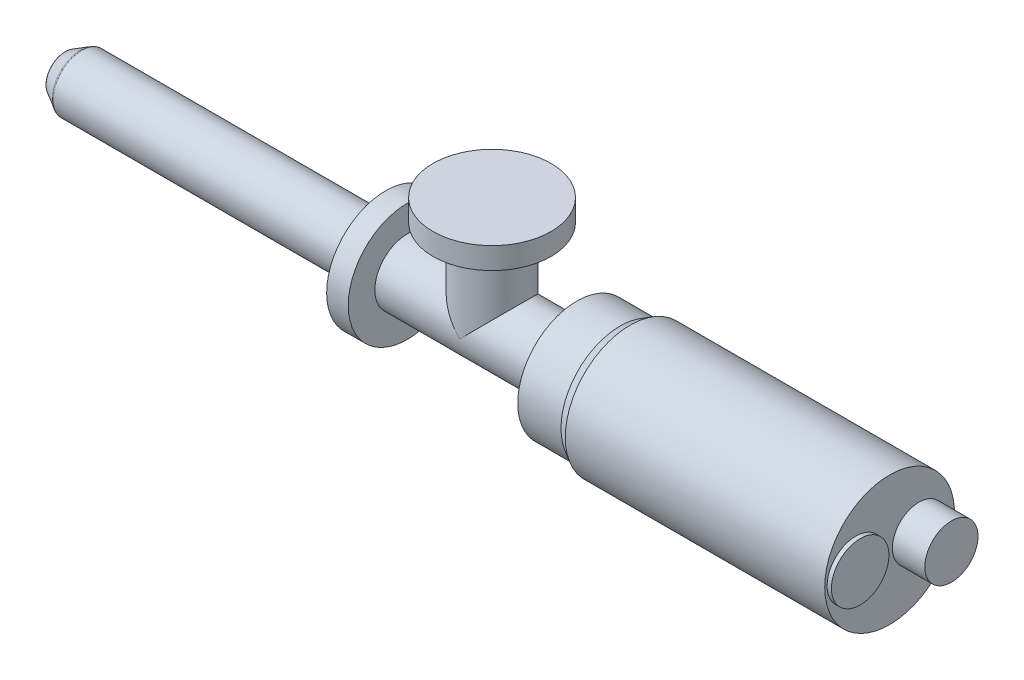
from build123d import *

# Parameters (mm, degrees)
SKETCH2_R           = 19.05
BOSS_EXTRUDE1_DEPTH = 62.484
SKETCH3_R           = 34.671
BOSS_EXTRUDE2_DEPTH = 12.7
SKETCH4_R           = 15.621
BOSS_EXTRUDE3_DEPTH = 19.05
SKETCH5_R           = 16.891
BOSS_EXTRUDE4_DEPTH = 2.54
FILLET1_R           = 1.524
SKETCH6_R           = 3.175
CUT_EXTRUDE1_DEPTH  = 12.7


with BuildPart() as part:
    # Sketch1 → Revolve1 (revolve)
    with BuildSketch(Plane.XY, mode=Mode.PRIVATE) as revolve1_sk:
        Polygon((0, 0), (0, 11.049), (9.722694003, 16.6624), (188.722, 16.6624), (188.722, 34.671), (201.422, 34.671), (201.422, 19.05), (300.99, 19.05), (300.99, 34.671), (326.39, 34.671), (332.329202219, 38.1), (484.729202219, 38.1), (484.729202219, 0), align=None)
    revolve(revolve1_sk.sketch.rotate(Axis((0, 0, 0), (1, 0, 0)), 90), axis=Axis((0, 0, 0), (1, 0, 0)))  # turned: the seam where the file's is

    # Sketch2 → Boss-Extrude1 (add)
    with BuildSketch(Plane(origin=(0, 0, 0), x_dir=(1, 0, 0), z_dir=(0, 1, 0))):
        with Locations(Location((251.206, 0, 0), (0, 0, 270))):  # turned: the seam where the file's is
            Circle(SKETCH2_R)
    extrude(amount=BOSS_EXTRUDE1_DEPTH)

    # Sketch3 → Boss-Extrude2 (add)
    with BuildSketch(Plane(origin=(0, 62.484, 0), x_dir=(1, 0, 0), z_dir=(0, 1, 0))):
        with Locations(Location((251.206, 0, 0), (0, 0, 270))):  # turned: the seam where the file's is
            Circle(SKETCH3_R)
    extrude(amount=-BOSS_EXTRUDE2_DEPTH)

    # Sketch4 → Boss-Extrude3 (add)
    with BuildSketch(Plane(origin=(484.729202219, 0, 0), x_dir=(0, 0, -1), z_dir=(1, 0, 0))):
        with Locations(Location((17.272, 0, 0), (0, 0, 180))):  # turned: the seam where the file's is
            Circle(SKETCH4_R)
    extrude(amount=BOSS_EXTRUDE3_DEPTH)

    # Sketch5 → Boss-Extrude4 (add)
    with BuildSketch(Plane(origin=(484.729202219, 0, 0), x_dir=(0, 0, -1), z_dir=(1, 0, 0))):
        with Locations(Location((-19.812, 0, 0), (0, 0, 180))):  # turned: the seam where the file's is
            Circle(SKETCH5_R)
    extrude(amount=BOSS_EXTRUDE4_DEPTH)

    # Fillet1
    fillet1_edges = [part.edges().sort_by_distance(p)[0] for p in [
        (9.722694003, 0, -16.6624),
        (0, 0, -11.049),
    ]]
    fillet(fillet1_edges, radius=FILLET1_R)

    # Sketch6 → Cut-Extrude1 (cut)
    with BuildSketch(Plane.ZY):
        Circle(SKETCH6_R)
    extrude(amount=-CUT_EXTRUDE1_DEPTH, mode=Mode.SUBTRACT)


solid = part.part
